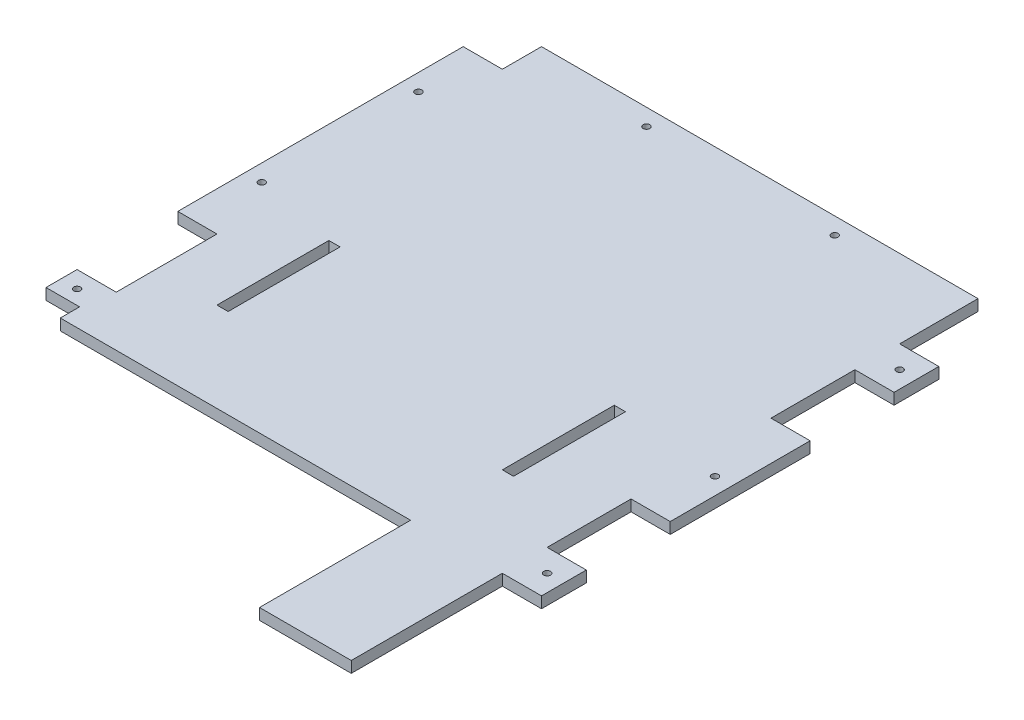
from build123d import *

# Parameters (mm, degrees)
SKETCH1_W           = 10
SKETCH1_H           = 100
BOSS_EXTRUDE1_DEPTH = 10
SKETCH2_R           = 3
SKETCH2_W           = 35
SKETCH2_H           = 70
SKETCH2_H_2         = 35
SKETCH2_H_3         = 90
SKETCH2_H_4         = 134.983592253
SKETCH2_H_5         = 75
CUT_EXTRUDE1_DEPTH  = 10


with BuildPart() as part:
    # Sketch1 → Boss-Extrude1 (new body)
    with BuildSketch(Plane(origin=(0, 0, 0), x_dir=(1, 0, 0), z_dir=(0, 1, 0))):
        Polygon((230, 560), (230, 0), (113, 0), (113, 135), (-200, 135), (-200, 152.241186389), (-230, 152.241186389), (-230, 560), align=None)
        with Locations((120, 265)):
            Rectangle(SKETCH1_W, SKETCH1_H, mode=Mode.SUBTRACT)
        with Locations((-135, 265)):
            Rectangle(SKETCH1_W, SKETCH1_H, mode=Mode.SUBTRACT)
    extrude(amount=BOSS_EXTRUDE1_DEPTH)

    # Sketch2 → Cut-Extrude1 (cut)
    with BuildSketch(Plane.XZ):
        with Locations((215, -470)):
            Circle(SKETCH2_R)
        with Locations((215, -155)):
            Circle(SKETCH2_R)
        with Locations((215, -305)):
            Circle(SKETCH2_R)
        with Locations((-215, -165)):
            Circle(SKETCH2_R)
        with Locations((-215, -470)):
            Circle(SKETCH2_R)
        with Locations((-215, -330)):
            Circle(SKETCH2_R)
        with Locations((81.96618504, -545)):
            Circle(SKETCH2_R)
        with Locations((-86.233971822, -545)):
            Circle(SKETCH2_R)
        with Locations((212.5, -525)):
            Rectangle(SKETCH2_W, SKETCH2_H)
        with Locations((-212.5, -542.5)):
            Rectangle(SKETCH2_W, SKETCH2_H_2)
        with Locations((-212.5, -225)):
            Rectangle(SKETCH2_W, SKETCH2_H_3)
        with Locations((212.5, -67.491796127)):
            Rectangle(SKETCH2_W, SKETCH2_H_4)
        with Locations((212.5, -212.5)):
            Rectangle(SKETCH2_W, SKETCH2_H_5)
        with Locations((212.5, -412.5)):
            Rectangle(SKETCH2_W, SKETCH2_H_5)
    extrude(amount=-CUT_EXTRUDE1_DEPTH, mode=Mode.SUBTRACT)


solid = part.part
